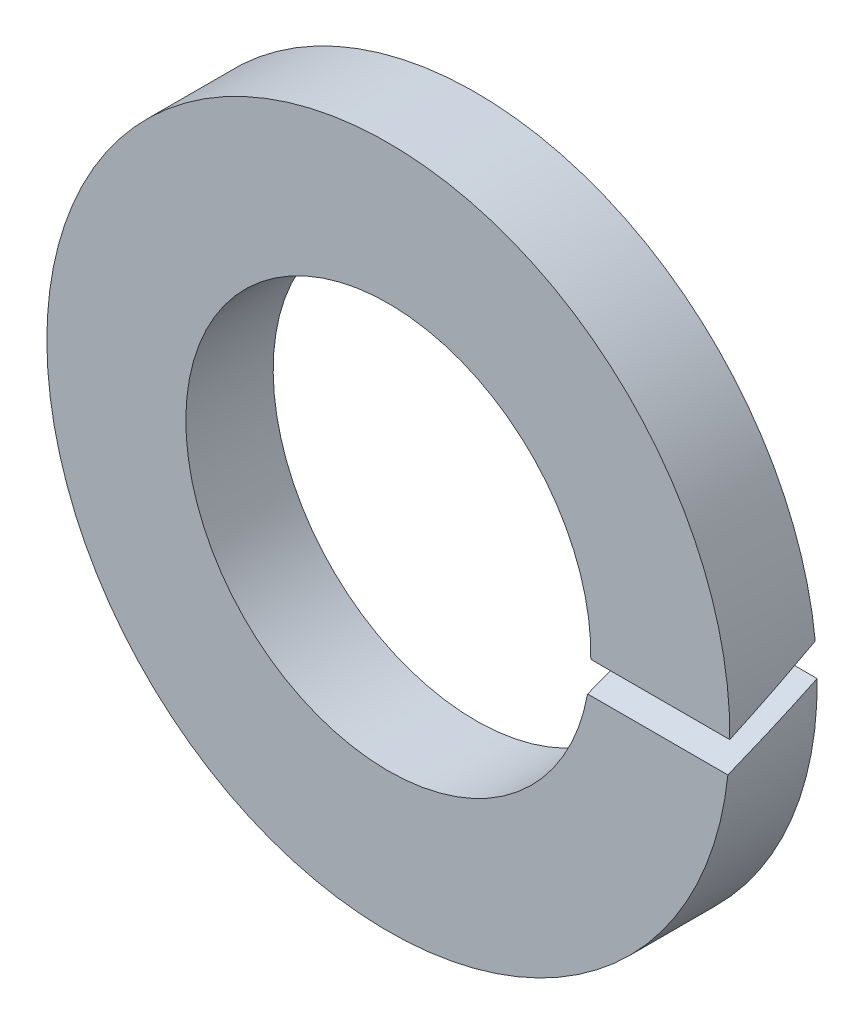
from build123d import *

# Parameters (mm, degrees)
SKICA1_R                 = 8.6
SKICA1_R_2               = 5.1
VYSUNOUT1_DEPTH          = 2.2
ODEBRAT_VYSUNUT_M1_DEPTH = 13.359611644


with BuildPart() as part:
    # Skica1 → Vysunout1 (new body)
    with BuildSketch(Plane.XY):
        Circle(SKICA1_R)
        Circle(SKICA1_R_2, mode=Mode.SUBTRACT)
    extrude(amount=VYSUNOUT1_DEPTH)

    # Skica2 → Odebrat vysunutím1 (cut, through all)
    with BuildSketch(Plane(origin=(0, 0, 0), x_dir=(0, 0, -1), z_dir=(1, 0, 0))):
        Polygon((0, 0.115722373), (-2.2, -0.910154475), (-2.2, -0.115722373), (0, 0.910154475), align=None)
    extrude(amount=ODEBRAT_VYSUNUT_M1_DEPTH, mode=Mode.SUBTRACT)


solid = part.part
